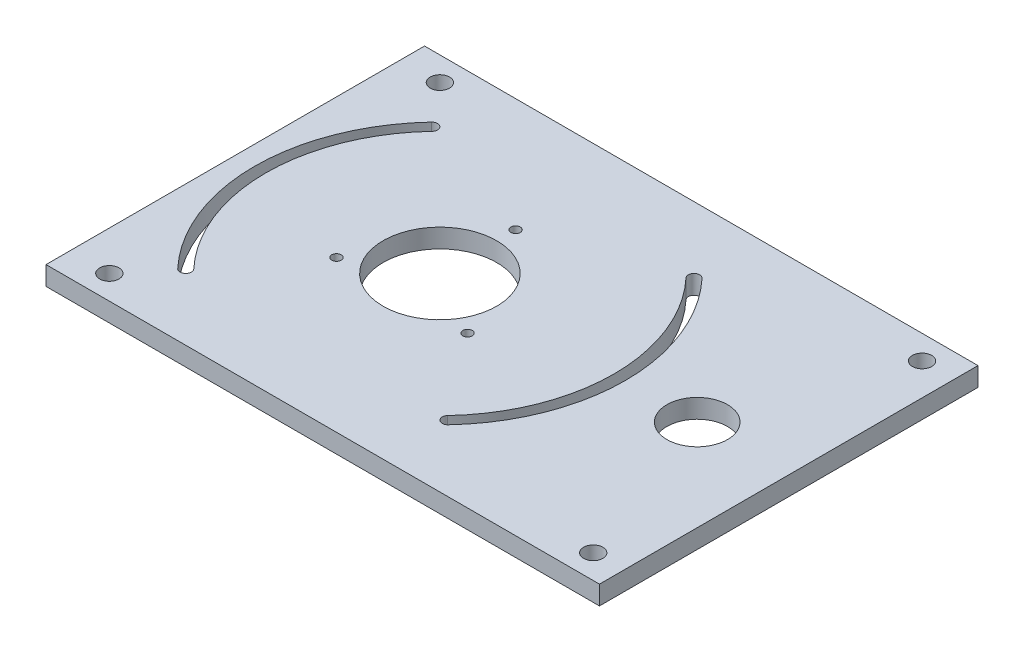
from build123d import *

# Parameters (mm, degrees)
SKETCH1_W                            = 146.211089784
SKETCH1_H                            = 100
SKETCH1_R                            = 1.25
SKETCH1_R_2                          = 8
SKETCH1_R_3                          = 15
BOSS_EXTRUDE1_DEPTH                  = 5
BOSS_EXTRUDE4_DEPTH                  = 11
BOSS_EXTRUDE4_2_DEPTH                = 11
TAP_DRILL_FOR_1_4_20_TAP1_AT_2_COUNT = 2
TAP_DRILL_FOR_1_4_20_TAP1_AT_2_PITCH = 87.325808516
TAP_DRILL_FOR_1_4_20_TAP1_AT_3_COUNT = 2
TAP_DRILL_FOR_1_4_20_TAP1_AT_3_PITCH = 154.434105625
TAP_DRILL_FOR_1_4_20_TAP1_AT_4_COUNT = 2
TAP_DRILL_FOR_1_4_20_TAP1_AT_4_PITCH = 127.833840476


with BuildPart() as part:
    # Sketch1 → Boss-Extrude1 (new body)
    with BuildSketch(Plane(origin=(0, 0, 0), x_dir=(1, 0, 0), z_dir=(0, 1, 0))):
        with Locations((19.05, -20)):
            Rectangle(SKETCH1_W, SKETCH1_H)
        with Locations((-17.312758334, -30.016899554)):
            Circle(SKETCH1_R, mode=Mode.SUBTRACT)
        with Locations((17.319248736, -30.009097211)):
            Circle(SKETCH1_R, mode=Mode.SUBTRACT)
        with Locations((67.999997057, -20.020005506)):
            Circle(SKETCH1_R_2, mode=Mode.SUBTRACT)
        with BuildLine():
            ThreePointArc((-33.537855017, 11.483523958), (-46, -19.999999986), (-33.537855037, -51.483523937))
            ThreePointArc((-33.537855037, -51.483523937), (-33.604844238, -53.603786249), (-35.725106552, -53.536797132))
            ThreePointArc((-35.725106552, -53.536797132), (-49, -19.99999995), (-35.725106483, 13.536797205))
            ThreePointArc((-35.725106483, 13.536797205), (-33.604844212, 13.603786224), (-33.537855017, 11.483523958))
        make_face(mode=Mode.SUBTRACT)
        with Locations((0, -20)):
            Circle(SKETCH1_R_3, mode=Mode.SUBTRACT)
        with Locations((0.000990516, -0.005201359)):
            Circle(SKETCH1_R, mode=Mode.SUBTRACT)
        with BuildLine():
            ThreePointArc((33.537855023, 11.483523952), (33.604844233, 13.603786244), (35.725106529, 13.536797156))
            ThreePointArc((35.725106529, 13.536797156), (49, -19.999999991), (35.725106542, -53.536797143))
            ThreePointArc((35.725106542, -53.536797143), (33.604844119, -53.603786137), (33.537855251, -51.48352371))
            ThreePointArc((33.537855251, -51.48352371), (46, -19.999999834), (33.537855023, 11.483523952))
        make_face(mode=Mode.SUBTRACT)
    extrude(amount=BOSS_EXTRUDE1_DEPTH)

    # Sketch3 → Tap Drill for 1_4-20 Tap1 (revolve, cut)
    with BuildSketch(Plane(origin=(-43.662904258, 0, 63.662904258), x_dir=(0, 0, -1), z_dir=(1, 0, 0))):
        Polygon((0, 0), (0, 26.933816902), (2.5527, 25.4), (2.5527, 0), align=None)
    tap_drill_for_1_4_20_tap1 = revolve(axis=Axis((-43.662904258, -6.35, 63.662904258), (0, 1, 0)), mode=Mode.SUBTRACT)

    # Tap Drill for 1_4-20 Tap1 at 2: Tap Drill for 1_4-20 Tap1 ×2
    with Locations(*[(0, 0, -i * TAP_DRILL_FOR_1_4_20_TAP1_AT_2_PITCH) for i in range(1, TAP_DRILL_FOR_1_4_20_TAP1_AT_2_COUNT)]):
        add(tap_drill_for_1_4_20_tap1, mode=Mode.SUBTRACT)

    # Tap Drill for 1_4-20 Tap1 at 3: Tap Drill for 1_4-20 Tap1 ×2
    with Locations(*[Vector(0.824777944, 0, -0.565456757) * (i * TAP_DRILL_FOR_1_4_20_TAP1_AT_3_PITCH) for i in range(1, TAP_DRILL_FOR_1_4_20_TAP1_AT_3_COUNT)]):
        add(tap_drill_for_1_4_20_tap1, mode=Mode.SUBTRACT)

    # Tap Drill for 1_4-20 Tap1 at 4: Tap Drill for 1_4-20 Tap1 ×2
    with Locations(*[(i * TAP_DRILL_FOR_1_4_20_TAP1_AT_4_PITCH, 0, 0) for i in range(1, TAP_DRILL_FOR_1_4_20_TAP1_AT_4_COUNT)]):
        add(tap_drill_for_1_4_20_tap1, mode=Mode.SUBTRACT)


with BuildPart() as body_2:
    # Sketch1_4 → Boss-Extrude4 (new body)
    with BuildSketch(Plane(origin=(0, 0, 0), x_dir=(1, 0, 0), z_dir=(0, 1, 0))):
        with BuildLine():
            ThreePointArc((-25.513706898, 13.299448349), (-41.95, -20), (-25.513706898, -53.299448349))
            Line((-25.513706898, -53.299448349), (-25.513706898, -50.806667477))
            ThreePointArc((-25.513706898, -50.806667477), (-40.000000009, -20), (-25.513706898, 10.806667477))
            Line((-25.513706898, 10.806667477), (-25.513706898, 13.299448349))
        make_face()
    extrude(amount=-BOSS_EXTRUDE4_DEPTH)


with BuildPart() as body_3:
    # Sketch1_4 → Boss-Extrude4 2 (new body)
    with BuildSketch(Plane(origin=(0, 0, 0), x_dir=(1, 0, 0), z_dir=(0, 1, 0))):
        with BuildLine():
            Line((25.513706898, -50.806667477), (25.513706898, -53.299448349))
            ThreePointArc((25.513706898, -53.299448349), (41.95, -20), (25.513706898, 13.299448349))
            Line((25.513706898, 13.299448349), (25.513706898, 10.806667477))
            ThreePointArc((25.513706898, 10.806667477), (40.000000009, -20), (25.513706898, -50.806667477))
        make_face()
    extrude(amount=-BOSS_EXTRUDE4_2_DEPTH)


solid = Compound([part.part, body_2.part, body_3.part])
